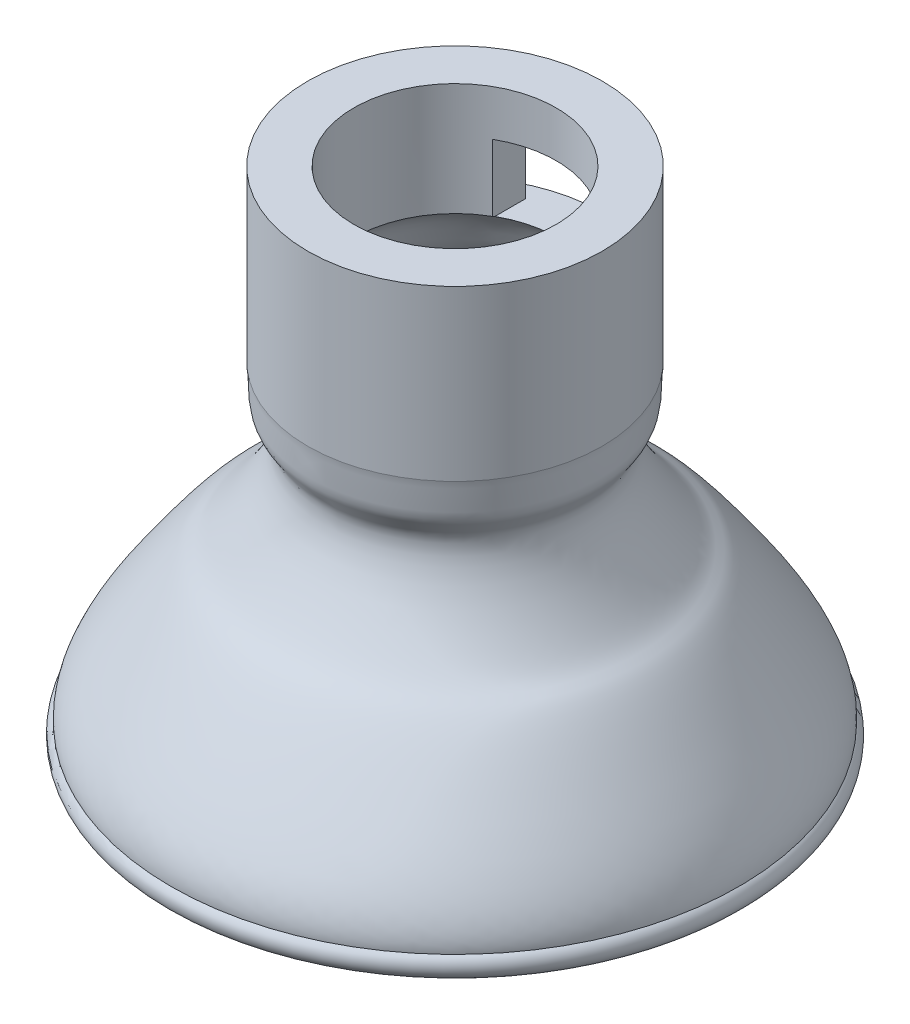
from build123d import *

# Parameters (mm, degrees)
ESBO_O2_W                  = 8.52075949
ESBO_O2_H                  = 5.764043184
CORTE_EXTRUS_O1_DEPTH      = 21
ESBO_O3_W                  = 2.243810292
ESBO_O3_H                  = 5.764043184
CORTE_EXTRUS_O2_DEPTH      = 21
CORTE_EXTRUS_O2_DEPTH_BACK = 21


with BuildPart() as part:
    # Esboço1 → Revolução1 (revolve)
    with BuildSketch(Plane.XY):
        with BuildLine():
            Line((12.493596339, 41.646579704), (12.493596339, 41.459883591))
            add(Edge.make_bspline(
                [(12.493596339, 41.459883591), (12.301263403, 40.198437894), (12.672676028, 38.232307085), (9.898226855, 35.869637873), (14.859497628, 27.808367469), (16.089859378, 28.020832476), (19.354182401, 24.142981418), (24.256577419, 16.859591957), (24.078601749, 14.91422611)],
                knots=[0, 0, 0, 0, 0.101004703, 0.175039834, 0.372875088, 0.603292123, 0.835962091, 1, 1, 1, 1], degree=3))
            ThreePointArc((24.078601749, 14.91422611), (23.296290883, 12.948863246), (22.883592364, 15.023553924))
            add(Edge.make_bspline(
                [(11.307306068, 41.640757561), (11.273508042, 41.419087908), (11.225101504, 40.957376107), (11.193026279, 40.152209665), (11.194025164, 39.304088475), (11.110574296, 38.777078707), (11.029809991, 38.585113078), (10.875626346, 38.330661384), (10.632782714, 37.993206106), (10.337880773, 37.554240715), (10.043589267, 36.9656871), (9.826027372, 36.007636699), (9.914556574, 34.890335952), (10.296489153, 33.575292999), (10.86389191, 32.293618099), (11.759071388, 30.664468375), (12.946367341, 28.919920551), (13.948802762, 27.69653267), (14.801409404, 26.960382807), (15.418667293, 26.577059231), (15.841844965, 26.255748079), (16.589552393, 25.48932973), (17.62963193, 24.220510979), (19.000727557, 22.369544481), (20.544370852, 20.200784471), (21.712928806, 18.335896373), (22.302975554, 17.206719637), (22.637852499, 16.382278959), (22.808730433, 15.829198344), (22.890769285, 15.346757355), (22.894284366, 15.140423019), (22.883592364, 15.023553924)],
                knots=[0, 0, 0, 0, 0.015625, 0.03125, 0.0625, 0.09375, 0.109375, 0.125, 0.140625, 0.15625, 0.171875, 0.1875, 0.21875, 0.25, 0.28125, 0.3125, 0.375, 0.4375, 0.5, 0.5625, 0.625, 0.6875, 0.75, 0.8125, 0.875, 0.90625, 0.9375, 0.953125, 0.96875, 0.984375, 1, 1, 1, 1], degree=3))
            add(Edge.make_bspline(
                [(11.307306068, 41.640757561), (10.493329038, 43.239681157), (10.332192588, 45.29403191), (8.575926678, 46.236967031)],
                knots=[0, 0, 0, 0, 1, 1, 1, 1], degree=3))
            Line((8.575926678, 46.236967031), (8.575926678, 55.780385677))
            Line((8.575926678, 55.780385677), (12.493596339, 55.780385677))
            Line((12.493596339, 55.780385677), (12.493596339, 46.236967031))
            Line((12.493596339, 46.236967031), (12.493596339, 41.646579704))
        make_face()
    revolve(axis=Axis((0, 44.517371893, 0), (0, -1, 0)))

    # Esboço2 → Corte-extrusão1 (cut)
    with BuildSketch(Plane.XY):
        with Locations((0, 49.017313479)):
            Rectangle(ESBO_O2_W, ESBO_O2_H)
    extrude(amount=-CORTE_EXTRUS_O1_DEPTH, mode=Mode.SUBTRACT)

    # Esboço3 → Corte-extrusão2 (cut, two sides)
    with BuildSketch(Plane(origin=(0, 0, 0), x_dir=(0, 0, -1), z_dir=(1, 0, 0))) as corte_extrus_o2_sk:
        with Locations((11.371691193, 49.017313479)):
            Rectangle(ESBO_O3_W, ESBO_O3_H)
    extrude(amount=CORTE_EXTRUS_O2_DEPTH, mode=Mode.SUBTRACT)
    extrude(corte_extrus_o2_sk.sketch, amount=-CORTE_EXTRUS_O2_DEPTH_BACK, mode=Mode.SUBTRACT)


solid = part.part
